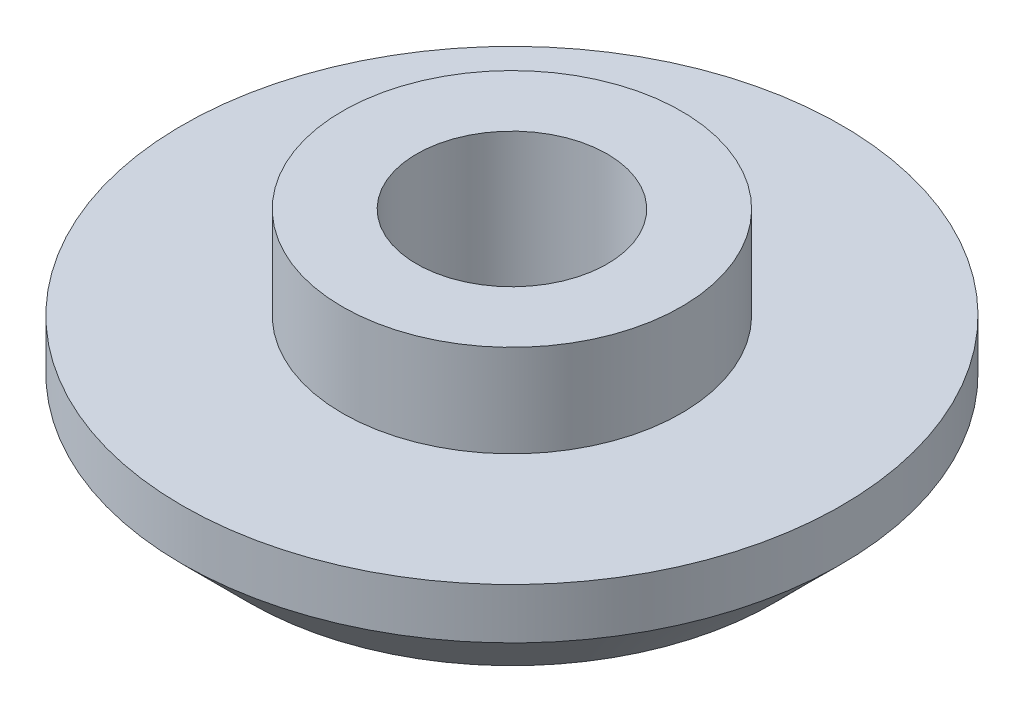
from build123d import *

# Parameters (mm, degrees)
SKETCH2_R          = 2
CUT_EXTRUDE1_DEPTH = 4.81


with BuildPart() as part:
    # Sketch1 → Revolve1 (revolve)
    with BuildSketch(Plane.XY):
        Polygon((0, 0.6), (3.5, 0.6), (3.5, 0), (5.5, 0), (6.914213562, 1.414213562), (6.914213562, 2.475397075), (3.556, 2.475397075), (3.556, 4.41), (0, 4.41), align=None)
    revolve(axis=Axis((0, 4.41, 0), (0, -1, 0)))

    # Sketch2 → Cut-Extrude1 (cut, through all)
    with BuildSketch(Plane.XZ.offset(-0.6)):
        Circle(SKETCH2_R)
    extrude(amount=-CUT_EXTRUDE1_DEPTH, mode=Mode.SUBTRACT)


solid = part.part
